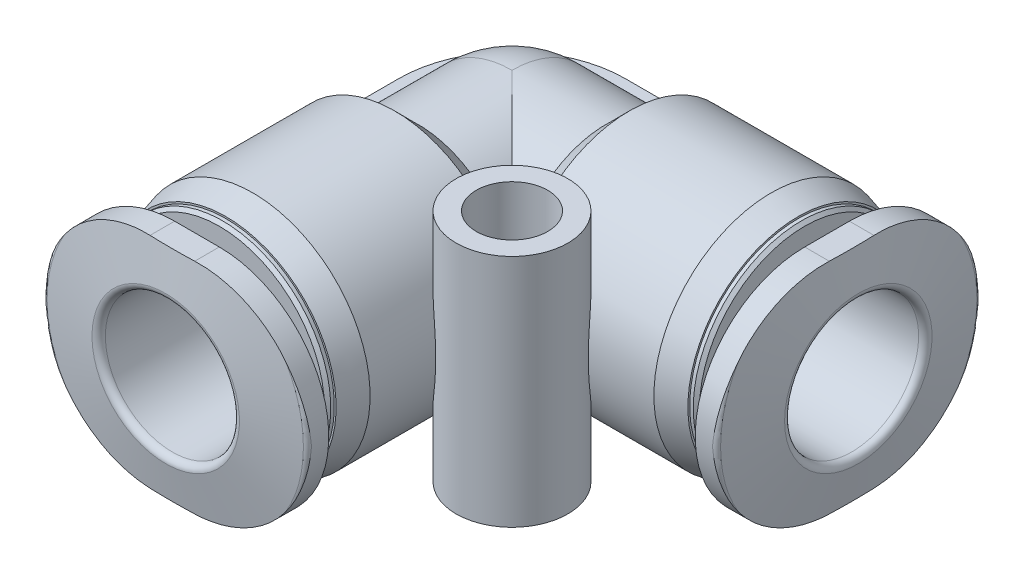
from build123d import *

# Parameters (mm, degrees)
SCHNITT_LINEAR_AUSTRAGEN1_DEPTH      = 1.4
AUFSATZ_LINEAR_AUSTRAGEN1_DEPTH      = 5.25
AUFSATZ_LINEAR_AUSTRAGEN2_DEPTH      = 5.25
SCHNITT_LINEAR_AUSTRAGEN2_DEPTH      = 1.4
SKIZZE9_R                            = 2.5
AUFSATZ_LINEAR_AUSTRAGEN3_DEPTH      = 5.25
AUFSATZ_LINEAR_AUSTRAGEN3_DEPTH_BACK = 5.25
BOHRUNG1_D                           = 3.2
BOHRUNG1_DEPTH                       = 11.5
ROTATION3_ANGLE                      = 90


with BuildPart() as part:
    # Skizze1 → Rotation1 (revolve)
    with BuildSketch(Plane.XY):
        with BuildLine():
            Line((0, 4.2), (4.2, 4.2))
            Line((4.2, 4.2), (5.25, 5.25))
            Line((5.25, 5.25), (11.6, 5.25))
            Line((11.6, 5.25), (12.8, 4.928460969))
            Line((12.8, 4.928460969), (12.8, 4.848076211))
            Line((12.8, 4.848076211), (12.958578644, 4.848076211))
            Line((12.958578644, 4.848076211), (13.1, 4.706654855))
            Line((13.1, 4.706654855), (13.1, 3.7))
            Line((13.1, 3.7), (13.73, 3.7))
            ThreePointArc((13.73, 3.7), (13.991629509, 3.808370491), (14.1, 4.07))
            Line((14.1, 4.07), (14.1, 5.9))
            Line((14.1, 5.9), (14.873729924, 5.9))
            ThreePointArc((14.873729924, 5.9), (15.002287446, 5.853208889), (15.070691475, 5.734729636))
            Line((15.070691475, 5.734729636), (15.5, 3.3))
            Line((15.5, 3.3), (15.5, 0))
            Line((15.5, 0), (-4.2, 0))
            ThreePointArc((-4.2, 0), (-2.969848481, 2.969848481), (0, 4.2))
        make_face()
    revolve(axis=Axis((15.5, 0, 0), (-1, 0, 0)))

    # Skizze2 → Schnitt-Linear austragen1 (cut)
    with BuildSketch(Plane(origin=(15.5, 0, 0), x_dir=(0, 0, -1), z_dir=(1, 0, 0))):
        Polygon((-7.08, -4.087639906), (0, -8.175279812), (7.08, -4.087639906), (7.08, 4.087639906), (0, 8.175279812), (-7.08, 4.087639906), align=None)
        with BuildLine():
            Line((-1, -4.9), (1, -4.9))
            ThreePointArc((1, -4.9), (4.464823228, -3.464823228), (5.9, 0))
            ThreePointArc((5.9, 0), (4.464823228, 3.464823228), (1, 4.9))
            Line((1, 4.9), (-1, 4.9))
            ThreePointArc((-1, 4.9), (-4.464823228, 3.464823228), (-5.9, 0))
            ThreePointArc((-5.9, 0), (-4.464823228, -3.464823228), (-1, -4.9))
        make_face(mode=Mode.SUBTRACT)
    extrude(amount=-SCHNITT_LINEAR_AUSTRAGEN1_DEPTH, mode=Mode.SUBTRACT)

    # Skizze3 → Aufsatz-Linear austragen1 (add)
    with BuildSketch(Plane(origin=(0, 0, 0), x_dir=(0, 0, -1), z_dir=(1, 0, 0))):
        with BuildLine():
            Line((-5.077865912, -1.333333333), (5.077865912, -1.333333333))
            ThreePointArc((5.077865912, -1.333333333), (5.25, 0), (5.077865912, 1.333333333))
            Line((5.077865912, 1.333333333), (-5.077865912, 1.333333333))
            ThreePointArc((-5.077865912, 1.333333333), (-5.25, 0), (-5.077865912, -1.333333333))
        make_face()
    extrude(amount=AUFSATZ_LINEAR_AUSTRAGEN1_DEPTH)

    # Skizze5 → Aufsatz-Linear austragen2 (add)
    with BuildSketch(Plane.XY):
        with BuildLine():
            Line((-5.077865912, -1.333333333), (0, -1.333333333))
            Line((0, -1.333333333), (0, 1.333333333))
            Line((0, 1.333333333), (-5.077865912, 1.333333333))
            ThreePointArc((-5.077865912, 1.333333333), (-5.25, 0), (-5.077865912, -1.333333333))
        make_face()
    extrude(amount=AUFSATZ_LINEAR_AUSTRAGEN2_DEPTH)

    # Skizze6 → Rotation2 (revolve)
    with BuildSketch(Plane(origin=(0, 0, 0), x_dir=(0, 0, -1), z_dir=(1, 0, 0))):
        with BuildLine():
            Line((0, 0), (0, -4.2))
            Line((0, -4.2), (-4.2, -4.2))
            Line((-4.2, -4.2), (-5.25, -5.25))
            Line((-5.25, -5.25), (-11.6, -5.25))
            Line((-11.6, -5.25), (-12.8, -4.928460969))
            Line((-12.8, -4.928460969), (-12.8, -4.848076211))
            Line((-12.8, -4.848076211), (-12.958578644, -4.848076211))
            Line((-12.958578644, -4.848076211), (-13.1, -4.706654855))
            Line((-13.1, -4.706654855), (-13.1, -3.7))
            Line((-13.1, -3.7), (-13.73, -3.7))
            ThreePointArc((-13.73, -3.7), (-13.991629509, -3.808370491), (-14.1, -4.07))
            Line((-14.1, -4.07), (-14.1, -5.9))
            Line((-14.1, -5.9), (-14.873729924, -5.9))
            ThreePointArc((-14.873729924, -5.9), (-15.002287446, -5.853208889), (-15.070691475, -5.734729636))
            Line((-15.070691475, -5.734729636), (-15.5, -3.3))
            Line((-15.5, -3.3), (-15.5, 0))
            Line((-15.5, 0), (0, 0))
        make_face()
    revolve(axis=Axis((0, 0, 15.5), (0, 0, -1)))

    # Skizze7 → Schnitt-Linear austragen2 (cut)
    with BuildSketch(Plane.XY.offset(15.5)):
        Polygon((-7.08, -4.087639906), (0, -8.175279812), (7.08, -4.087639906), (7.08, 4.087639906), (0, 8.175279812), (-7.08, 4.087639906), align=None)
        with BuildLine():
            Line((-1, -4.9), (1, -4.9))
            ThreePointArc((1, -4.9), (4.464823228, -3.464823228), (5.9, 0))
            ThreePointArc((5.9, 0), (4.464823228, 3.464823228), (1, 4.9))
            Line((1, 4.9), (-1, 4.9))
            ThreePointArc((-1, 4.9), (-4.464823228, 3.464823228), (-5.9, 0))
            ThreePointArc((-5.9, 0), (-4.464823228, -3.464823228), (-1, -4.9))
        make_face(mode=Mode.SUBTRACT)
    extrude(amount=-SCHNITT_LINEAR_AUSTRAGEN2_DEPTH, mode=Mode.SUBTRACT)

    # Skizze9 → Aufsatz-Linear austragen3 (add, two sides)
    with BuildSketch(Plane(origin=(0, 0, 0), x_dir=(1, 0, 0), z_dir=(0, 1, 0))) as aufsatz_linear_austragen3_sk:
        with Locations((6.5, -6.5)):
            Circle(SKIZZE9_R)
    extrude(amount=AUFSATZ_LINEAR_AUSTRAGEN3_DEPTH)
    extrude(aufsatz_linear_austragen3_sk.sketch, amount=-AUFSATZ_LINEAR_AUSTRAGEN3_DEPTH_BACK)

    # Bohrung1
    with Locations(Plane(origin=(0, 5.25, 0), x_dir=(1, 0, 0), z_dir=(0, 1, 0))):
        with Locations((6.5, -6.5)):
            Hole(BOHRUNG1_D / 2, depth=BOHRUNG1_DEPTH)

    # Skizze12 → Rotation3 (revolve)
    with BuildSketch(Plane(origin=(0, 0, 0), x_dir=(0, 0, -1), z_dir=(1, 0, 0))):
        with BuildLine():
            Line((0, 1.333333333), (5.077865912, 1.333333333))
            ThreePointArc((5.077865912, 1.333333333), (5.25, 0), (5.077865912, -1.333333333))
            Line((5.077865912, -1.333333333), (0, -1.333333333))
            Line((0, -1.333333333), (0, 1.333333333))
        make_face()
    revolve(axis=Axis((0, -1.333333333, 0), (0, 1, 0)), revolution_arc=ROTATION3_ANGLE)

    # Skizze8 → Schnitt-Rotation1 (revolve, cut)
    with BuildSketch(Plane(origin=(0, 0, 0), x_dir=(0, 0, -1), z_dir=(1, 0, 0))):
        with BuildLine():
            Line((0, 0), (0, -2))
            Line((0, -2), (-3.5, -2))
            Line((-3.5, -2), (-3.5, -2.8))
            ThreePointArc((-3.5, -2.8), (-3.558578644, -2.941421356), (-3.7, -3))
            Line((-3.7, -3), (-15.2, -3))
            ThreePointArc((-15.2, -3), (-15.412132034, -3.087867966), (-15.5, -3.3))
            Line((-15.5, -3.3), (-15.5, 0))
            Line((-15.5, 0), (0, 0))
        make_face()
    revolve(axis=Axis((0, 0, 15.5), (0, 0, -1)), mode=Mode.SUBTRACT)

    # Skizze4 → Schnitt-Rotation2 (revolve, cut)
    with BuildSketch(Plane(origin=(0, 0, 0), x_dir=(1, 0, 0), z_dir=(0, 1, 0))):
        with BuildLine():
            Line((0, 2), (3.5, 2))
            Line((3.5, 2), (3.5, 2.8))
            ThreePointArc((3.5, 2.8), (3.558578644, 2.941421356), (3.7, 3))
            Line((3.7, 3), (15.2, 3))
            ThreePointArc((15.2, 3), (15.412132034, 3.087867966), (15.5, 3.3))
            Line((15.5, 3.3), (15.5, 0))
            Line((15.5, 0), (-2, 0))
            ThreePointArc((-2, 0), (-1.414213562, 1.414213562), (0, 2))
        make_face()
    revolve(axis=Axis((15.5, 0, 0), (-1, 0, 0)), mode=Mode.SUBTRACT)


solid = part.part
